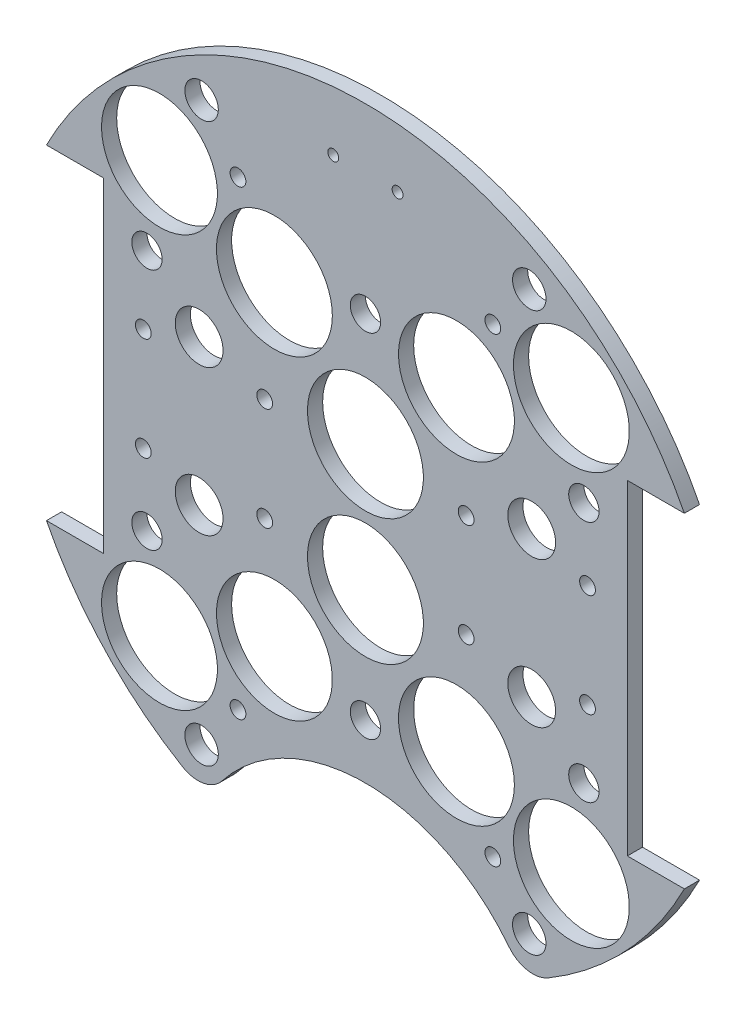
from build123d import *

# Parameters (mm, degrees)
SKETCH1_R               = 1.651
BOSS_EXTRUDE2_DEPTH     = 3.175
SKETCH2_R               = 1.143
CUT_EXTRUDE1_DEPTH      = 101.402396032
SKETCH3_R               = 12.1285
CUT_EXTRUDE2_DEPTH      = 101.402396032
SKETCH4_R               = 38.1
CUT_EXTRUDE3_DEPTH      = 124.46
SKETCH5_R               = 5
CUT_EXTRUDE4_DEPTH      = 101.402396032
SKETCH6_R               = 1.651
CUT_EXTRUDE5_DEPTH      = 223.668813424
SKETCH7_R               = 3.175
CUT_EXTRUDE6_DEPTH      = 226.368754426
CUT_EXTRUDE6_DEPTH_BACK = 226.368754426
FILLET1_R               = 6.35
SKETCH8_R               = 1.651
CUT_EXTRUDE7_DEPTH      = 29.21
SKETCH9_R               = 3.5
CUT_EXTRUDE8_DEPTH      = 101.402396176


with BuildPart() as part:
    # Sketch1 → Boss-Extrude2 (new body)
    with BuildSketch(Plane.XY):
        with BuildLine():
            Line((-66.753693561, 34.036), (-54.815693561, 34.036))
            Line((-54.815693561, 34.036), (-54.815693561, -34.036))
            Line((-54.815693561, -34.036), (-66.753693561, -34.036))
            ThreePointArc((-66.753693561, -34.036), (0, -74.93), (66.753693561, -34.036))
            Line((66.753693561, -34.036), (54.815693561, -34.036))
            Line((54.815693561, -34.036), (54.815693561, 34.036))
            Line((54.815693561, 34.036), (66.753693561, 34.036))
            ThreePointArc((66.753693561, 34.036), (0, 74.93), (-66.753693561, 34.036))
        make_face()
        with Locations((-46.482, 10.795)):
            Circle(SKETCH1_R, mode=Mode.SUBTRACT)
        with Locations((-21.082, 10.795)):
            Circle(SKETCH1_R, mode=Mode.SUBTRACT)
        with Locations(Location((-21.082, -10.795, 0), (0, 0, 180))):
            Circle(SKETCH1_R, mode=Mode.SUBTRACT)
        with Locations(Location((-46.482, -10.795, 0), (0, 0, 180))):
            Circle(SKETCH1_R, mode=Mode.SUBTRACT)
        with Locations((46.482, -10.795)):
            Circle(SKETCH1_R, mode=Mode.SUBTRACT)
        with Locations((21.082, -10.795)):
            Circle(SKETCH1_R, mode=Mode.SUBTRACT)
        with Locations(Location((21.082, 10.795, 0), (0, 0, 180))):
            Circle(SKETCH1_R, mode=Mode.SUBTRACT)
        with Locations(Location((46.482, 10.795, 0), (0, 0, 180))):
            Circle(SKETCH1_R, mode=Mode.SUBTRACT)
    extrude(amount=BOSS_EXTRUDE2_DEPTH)

    # Sketch2 → Cut-Extrude1 (cut, through all)
    with BuildSketch(Plane.XY.offset(3.175)):
        with Locations((-6.731, 62.23)):
            Circle(SKETCH2_R)
        with Locations(Location((6.731, 62.23, 0), (0, 0, 180))):
            Circle(SKETCH2_R)
    extrude(amount=-CUT_EXTRUDE1_DEPTH, mode=Mode.SUBTRACT)

    # Sketch3 → Cut-Extrude2 (cut, through all)
    with BuildSketch(Plane(origin=(0, 0, 0), x_dir=(-1, 0, 0), z_dir=(0, 0, -1))):
        with Locations((0, -13.208)):
            Circle(SKETCH3_R)
        with Locations((0, 13.208)):
            Circle(SKETCH3_R)
        with Locations((-43.105229381, -43.105229381)):
            Circle(SKETCH3_R)
        with Locations((19.05, -32.995567884)):
            Circle(SKETCH3_R)
        with Locations(Location((19.05, 32.995567884, 0), (0, 0, 180))):
            Circle(SKETCH3_R)
        with Locations((-43.105229381, 43.105229381)):
            Circle(SKETCH3_R)
        with Locations((43.105229381, 43.105229381)):
            Circle(SKETCH3_R)
        with Locations((-19.05, 32.995567884)):
            Circle(SKETCH3_R)
        with Locations(Location((-19.05, -32.995567884, 0), (0, 0, 180))):
            Circle(SKETCH3_R)
        with Locations((43.105229381, -43.105229381)):
            Circle(SKETCH3_R)
    extrude(amount=-CUT_EXTRUDE2_DEPTH, mode=Mode.SUBTRACT)

    # Sketch4 → Cut-Extrude3 (cut)
    with BuildSketch(Plane(origin=(0, 0, 0), x_dir=(-1, 0, 0), z_dir=(0, 0, -1))):
        with Locations((0, -86.312058398)):
            Circle(SKETCH4_R)
    extrude(amount=-CUT_EXTRUDE3_DEPTH, mode=Mode.SUBTRACT)

    # Sketch5 → Cut-Extrude4 (cut, through all)
    with BuildSketch(Plane(origin=(0, 0, 0), x_dir=(-1, 0, 0), z_dir=(0, 0, -1))):
        with Locations((34.798, -15.24)):
            Circle(SKETCH5_R)
        with Locations(Location((-34.798, -15.24, 0), (0, 0, 180))):
            Circle(SKETCH5_R)
        with Locations((-34.798, 15.24)):
            Circle(SKETCH5_R)
        with Locations(Location((34.798, 15.24, 0), (0, 0, 180))):
            Circle(SKETCH5_R)
    extrude(amount=-CUT_EXTRUDE4_DEPTH, mode=Mode.SUBTRACT)

    # Sketch6 → Cut-Extrude5 (cut, through all)
    with BuildSketch(Plane(origin=(31.313436391, 132.613959999, 0), x_dir=(0, 1, 0), z_dir=(0, 0, -1))):
        with Locations(Location((-180.873959999, -4.643436391, 0), (0, 0, 270))):
            Circle(SKETCH6_R)
        with Locations(Location((-180.873959999, -57.983436391, 0), (0, 0, 90))):
            Circle(SKETCH6_R)
        with Locations(Location((-84.353959999, -57.983436391, 0), (0, 0, 270))):
            Circle(SKETCH6_R)
        with Locations(Location((-84.353959999, -4.643436391, 0), (0, 0, 90))):
            Circle(SKETCH6_R)
    extrude(amount=-CUT_EXTRUDE5_DEPTH, mode=Mode.SUBTRACT)

    # Sketch7 → Cut-Extrude6 (cut, two sides)
    with BuildSketch(Plane(origin=(31.313436391, 132.613959999, -31.75), x_dir=(0, 1, 0), z_dir=(0, 0, -1))) as cut_extrude6_sk:
        with Locations((-158.013959999, 14.406563609)):
            Circle(SKETCH7_R)
        with Locations((-169.443959999, -31.313436391)):
            Circle(SKETCH7_R)
        with Locations((-158.013959999, -77.033436391)):
            Circle(SKETCH7_R)
        with Locations((-107.213959999, -77.033436391)):
            Circle(SKETCH7_R)
        with Locations((-95.783959999, -31.313436391)):
            Circle(SKETCH7_R)
        with Locations((-107.213959999, 14.406563609)):
            Circle(SKETCH7_R)
    extrude(amount=CUT_EXTRUDE6_DEPTH, mode=Mode.SUBTRACT)
    extrude(cut_extrude6_sk.sketch, amount=-CUT_EXTRUDE6_DEPTH_BACK, mode=Mode.SUBTRACT)

    # Fillet1
    fillet1_edges = [part.edges().sort_by_distance(p)[0] for p in [
        (33.000960548, -67.271401821, 1.5875),
        (-33.000960548, -67.271401821, 1.5875),
    ]]
    fillet(fillet1_edges, radius=FILLET1_R)

    # Sketch8 → Cut-Extrude7 (cut)
    with BuildSketch(Plane(origin=(31.313436391, 132.613959999, -28.575), x_dir=(0, 1, 0), z_dir=(0, 0, -1))):
        with Locations(Location((-191.033959999, 2.976563609, 0), (0, 0, 270))):
            Circle(SKETCH8_R)
        with Locations(Location((-191.033959999, -65.603436391, 0), (0, 0, 270))):
            Circle(SKETCH8_R)
        with Locations(Location((-74.193959999, -65.603436391, 0), (0, 0, 270))):
            Circle(SKETCH8_R)
        with Locations(Location((-74.193959999, 2.976563609, 0), (0, 0, 270))):
            Circle(SKETCH8_R)
    extrude(amount=-CUT_EXTRUDE7_DEPTH, mode=Mode.SUBTRACT)

    # Sketch9 → Cut-Extrude8 (cut, through all)
    with BuildSketch(Plane(origin=(0, 0, 0), x_dir=(-1, 0, 0), z_dir=(0, 0, -1))):
        with Locations((34.29, 58.42)):
            Circle(SKETCH9_R)
        with Locations((-34.29, 58.42)):
            Circle(SKETCH9_R)
        with Locations((-34.29, -58.42)):
            Circle(SKETCH9_R)
        with Locations((34.29, -58.42)):
            Circle(SKETCH9_R)
    extrude(amount=-CUT_EXTRUDE8_DEPTH, mode=Mode.SUBTRACT)


solid = part.part
